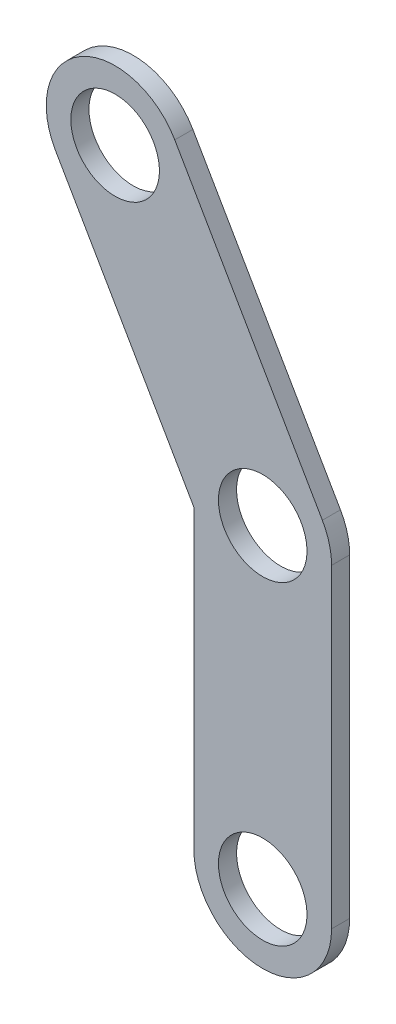
from build123d import *

# Parameters (mm, degrees)
SKETCH1_R           = 14.2875
BOSS_EXTRUDE1_DEPTH = 5.842


with BuildPart() as part:
    # Sketch1 → Boss-Extrude1 (new body)
    with BuildSketch(Plane(origin=(0, 0, 0), x_dir=(-1, 0, 0), z_dir=(0, 0, -1))):
        with BuildLine():
            Line((73.788575358, 2.063404121), (73.788575358, 97.70823332))
            Line((73.788575358, 97.70823332), (118.435989957, 175.039823832))
            ThreePointArc((118.435989957, 175.039823832), (110.301075358, 205.399738431), (79.941160759, 197.264823832))
            Line((79.941160759, 197.264823832), (32.316160759, 114.775904121))
            ThreePointArc((32.316160759, 114.775904121), (30.095873869, 109.415657399), (29.338575358, 103.663404121))
            Line((29.338575358, 103.663404121), (29.338575358, 2.063404121))
            ThreePointArc((29.338575358, 2.063404121), (51.563575358, -20.161595879), (73.788575358, 2.063404121))
        make_face()
        with Locations((51.563575358, 2.063404121)):
            Circle(SKETCH1_R, mode=Mode.SUBTRACT)
        with Locations((51.563575358, 103.663404121)):
            Circle(SKETCH1_R, mode=Mode.SUBTRACT)
        with Locations((99.188575358, 186.152323832)):
            Circle(SKETCH1_R, mode=Mode.SUBTRACT)
    extrude(amount=-BOSS_EXTRUDE1_DEPTH)


solid = part.part
